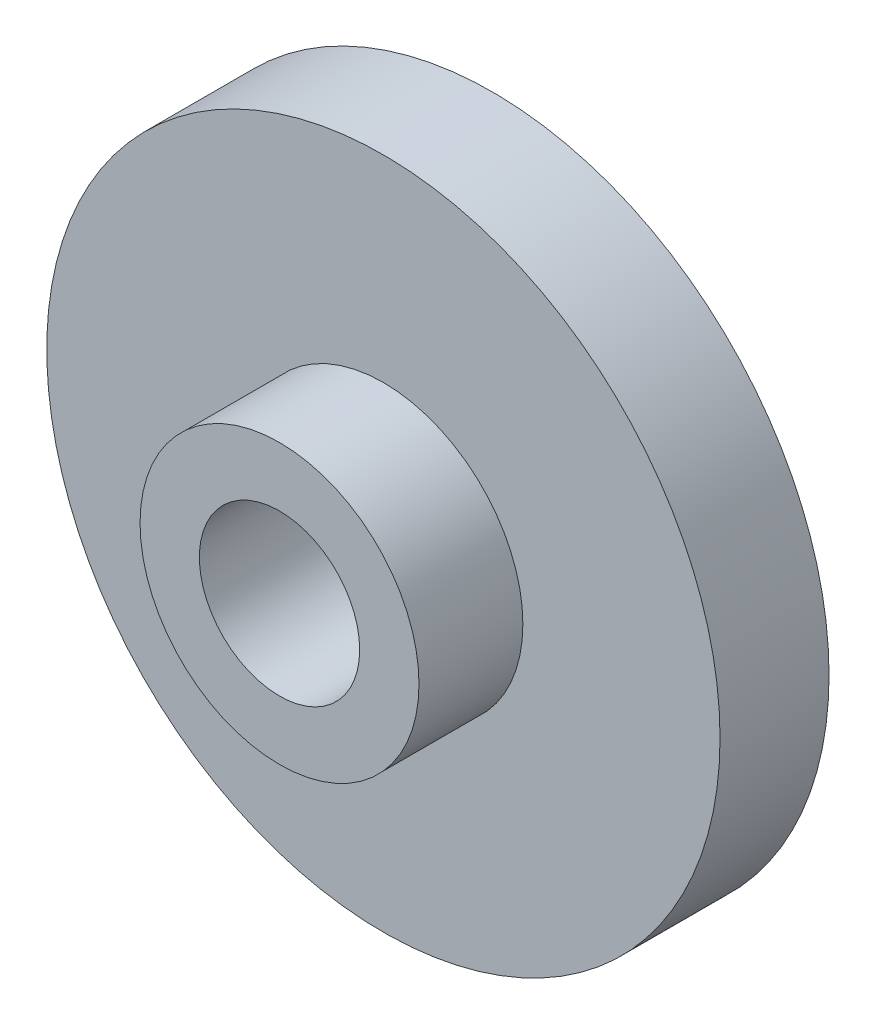
from build123d import *

# Parameters (mm, degrees)
CROQUIS1_R              = 10.5
SALIENTE_EXTRUIR1_DEPTH = 3.4
CROQUIS2_R              = 4.35
SALIENTE_EXTRUIR2_DEPTH = 3.24
CROQUIS3_R              = 2.5
CORTAR_EXTRUIR1_DEPTH   = 16.24


with BuildPart() as part:
    # Croquis1 → Saliente-Extruir1 (new body)
    with BuildSketch(Plane.XY):
        Circle(CROQUIS1_R)
    extrude(amount=SALIENTE_EXTRUIR1_DEPTH)

    # Croquis2 → Saliente-Extruir2 (add)
    with BuildSketch(Plane.XY.offset(3.4)):
        Circle(CROQUIS2_R)
    extrude(amount=SALIENTE_EXTRUIR2_DEPTH)

    # Croquis3 → Cortar-Extruir1 (cut)
    with BuildSketch(Plane.XY.offset(6.64)):
        Circle(CROQUIS3_R)
    extrude(amount=-CORTAR_EXTRUIR1_DEPTH, mode=Mode.SUBTRACT)


solid = part.part
